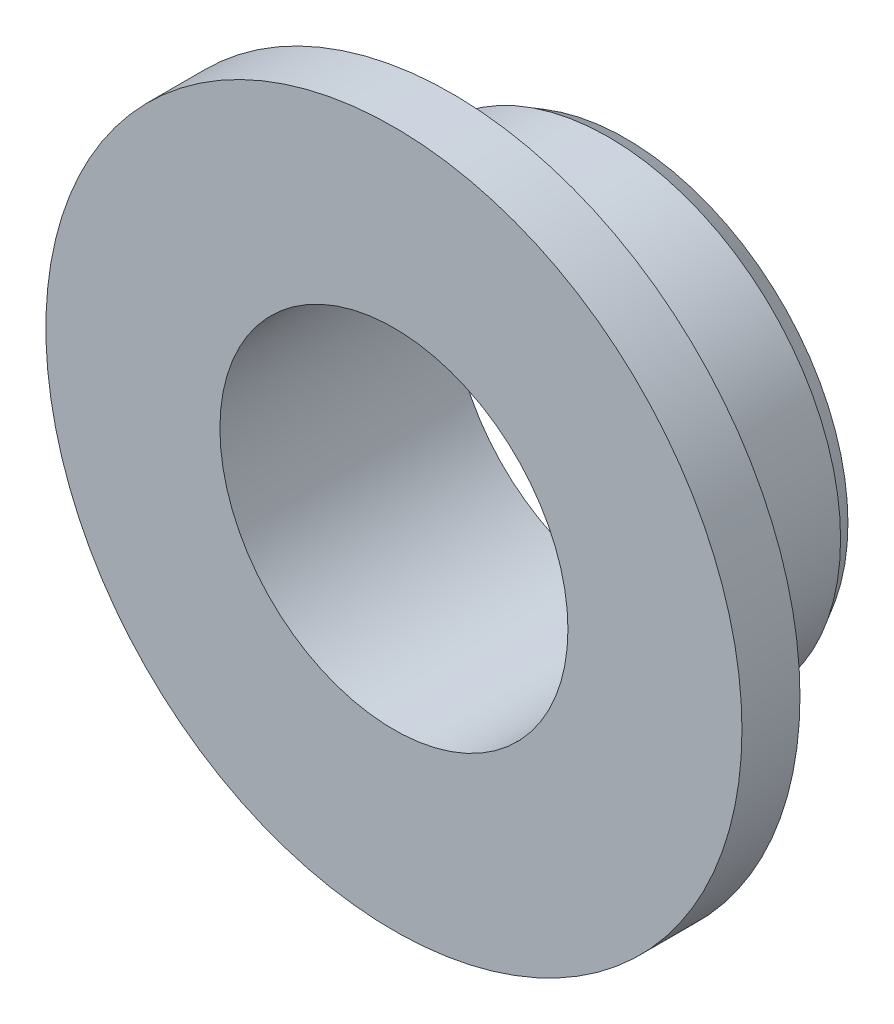
from build123d import *

# Parameters (mm, degrees)
SKETCH1_R           = 4
SKETCH1_R_2         = 3
BOSS_EXTRUDE1_DEPTH = 4
SKETCH2_R           = 6
SKETCH2_R_2         = 3
BOSS_EXTRUDE2_DEPTH = 1
FILLET1_R           = 0.5
CHAMFER1_SIZE       = 0.3
CHAMFER1_SIZE2      = 0.173205081


with BuildPart() as part:
    # Sketch1 → Boss-Extrude1 (new body)
    with BuildSketch(Plane.XY):
        Circle(SKETCH1_R)
        Circle(SKETCH1_R_2, mode=Mode.SUBTRACT)
    extrude(amount=BOSS_EXTRUDE1_DEPTH)

    # Sketch2 → Boss-Extrude2 (add)
    with BuildSketch(Plane.XY.offset(4)):
        Circle(SKETCH2_R)
        Circle(SKETCH2_R_2, mode=Mode.SUBTRACT)
    extrude(amount=-BOSS_EXTRUDE2_DEPTH)

    # Fillet1
    fillet1_edges = [part.edges().sort_by_distance(p)[0] for p in [
        (-4, 0, 3),
    ]]
    fillet(fillet1_edges, radius=FILLET1_R)

    # Chamfer1
    chamfer1_edges = [part.edges().sort_by_distance(p)[0] for p in [
        (-4, 0, 0),
    ]]
    chamfer1_side = [part.faces().sort_by_distance(p)[0] for p in [
        (-4, 0, 1.25),
    ]]
    chamfer(chamfer1_edges, length=CHAMFER1_SIZE, length2=CHAMFER1_SIZE2, reference=chamfer1_side[0])


solid = part.part
